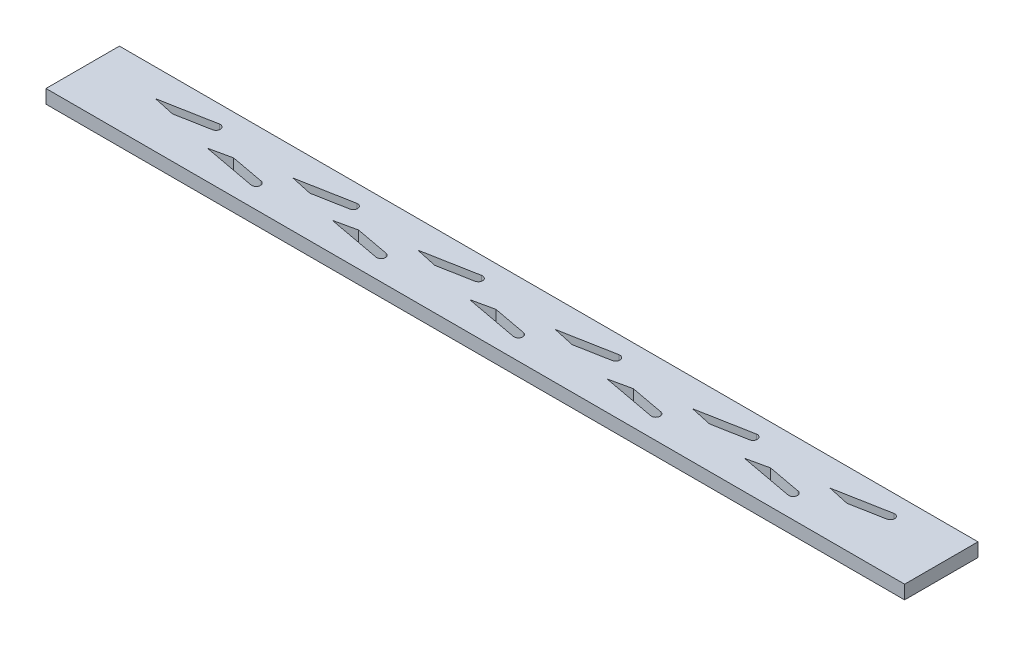
from build123d import *

# Parameters (mm, degrees)
SKETCH4_W           = 200
SKETCH4_H           = 17.1
BOSS_EXTRUDE2_DEPTH = 3.175
CUT_EXTRUDE3_DEPTH  = 3.175


with BuildPart() as part:
    # Sketch4 → Boss-Extrude2 (new body)
    with BuildSketch(Plane(origin=(0, 0, 0), x_dir=(1, 0, 0), z_dir=(0, 1, 0))):
        with Locations((100, 8.55)):
            Rectangle(SKETCH4_W, SKETCH4_H)
    extrude(amount=BOSS_EXTRUDE2_DEPTH)

    # Sketch5 → Cut-Extrude3 (cut)
    with BuildSketch(Plane(origin=(0, 3.175, 0), x_dir=(1, 0, 0), z_dir=(0, 1, 0))):
        with BuildLine():
            ThreePointArc((59.356356651, 13.033114886), (60.52246094, 12.232989403), (59.722335457, 11.066885114))
            Line((59.722335457, 11.066885114), (51.857416371, 9.602969892))
            Line((51.857416371, 9.602969892), (46.821641859, 10.7))
            Line((46.821641859, 10.7), (59.356356651, 13.033114886))
        make_face()
        with BuildLine():
            ThreePointArc((72.822542019, 6.383114886), (73.622667502, 5.217010597), (72.456563214, 4.416885114))
            Line((72.456563214, 4.416885114), (59.921848421, 6.75))
            Line((59.921848421, 6.75), (64.957622934, 7.847030108))
            Line((64.957622934, 7.847030108), (72.822542019, 6.383114886))
        make_face()
        with BuildLine():
            ThreePointArc((88.456563214, 13.033114886), (89.622667502, 12.232989403), (88.822542019, 11.066885114))
            Line((88.822542019, 11.066885114), (80.957622934, 9.602969892))
            Line((80.957622934, 9.602969892), (75.921848421, 10.7))
            Line((75.921848421, 10.7), (88.456563214, 13.033114886))
        make_face()
        with BuildLine():
            ThreePointArc((104.822542019, 6.383114886), (105.622667502, 5.217010597), (104.456563214, 4.416885114))
            Line((104.456563214, 4.416885114), (91.921848421, 6.75))
            Line((91.921848421, 6.75), (96.957622934, 7.847030108))
            Line((96.957622934, 7.847030108), (104.822542019, 6.383114886))
        make_face()
        with BuildLine():
            ThreePointArc((120.456563214, 13.033114886), (121.622667502, 12.232989403), (120.822542019, 11.066885114))
            Line((120.822542019, 11.066885114), (112.957622934, 9.602969892))
            Line((112.957622934, 9.602969892), (107.921848421, 10.7))
            Line((107.921848421, 10.7), (120.456563214, 13.033114886))
        make_face()
        with BuildLine():
            ThreePointArc((152.456563214, 13.033114886), (153.622667502, 12.232989403), (152.822542019, 11.066885114))
            Line((152.822542019, 11.066885114), (144.957622934, 9.602969892))
            Line((144.957622934, 9.602969892), (139.921848421, 10.7))
            Line((139.921848421, 10.7), (152.456563214, 13.033114886))
        make_face()
        with BuildLine():
            ThreePointArc((184.456563214, 13.033114886), (185.622667502, 12.232989403), (184.822542019, 11.066885114))
            Line((184.822542019, 11.066885114), (176.957622934, 9.602969892))
            Line((176.957622934, 9.602969892), (171.921848421, 10.7))
            Line((171.921848421, 10.7), (184.456563214, 13.033114886))
        make_face()
        with BuildLine():
            Line((14.821641859, 10.7), (19.857416371, 9.602969892))
            Line((19.857416371, 9.602969892), (27.722335457, 11.066885114))
            ThreePointArc((27.722335457, 11.066885114), (28.52246094, 12.232989403), (27.356356651, 13.033114886))
            Line((27.356356651, 13.033114886), (14.821641859, 10.7))
        make_face()
        with BuildLine():
            Line((35.857416371, 7.847030108), (43.722335457, 6.383114886))
            ThreePointArc((43.722335457, 6.383114886), (44.52246094, 5.217010597), (43.356356651, 4.416885114))
            Line((43.356356651, 4.416885114), (30.821641859, 6.75))
            Line((30.821641859, 6.75), (35.857416371, 7.847030108))
        make_face()
        with BuildLine():
            Line((128.957622934, 7.847030108), (136.822542019, 6.383114886))
            ThreePointArc((136.822542019, 6.383114886), (137.622667502, 5.217010597), (136.456563214, 4.416885114))
            Line((136.456563214, 4.416885114), (123.921848421, 6.75))
            Line((123.921848421, 6.75), (128.957622934, 7.847030108))
        make_face()
        with BuildLine():
            Line((155.921848421, 6.75), (168.456563214, 4.416885114))
            ThreePointArc((168.456563214, 4.416885114), (169.622667502, 5.217010597), (168.822542019, 6.383114886))
            Line((168.822542019, 6.383114886), (160.957622934, 7.847030108))
            Line((160.957622934, 7.847030108), (155.921848421, 6.75))
        make_face()
    extrude(amount=-CUT_EXTRUDE3_DEPTH, mode=Mode.SUBTRACT)


solid = part.part
